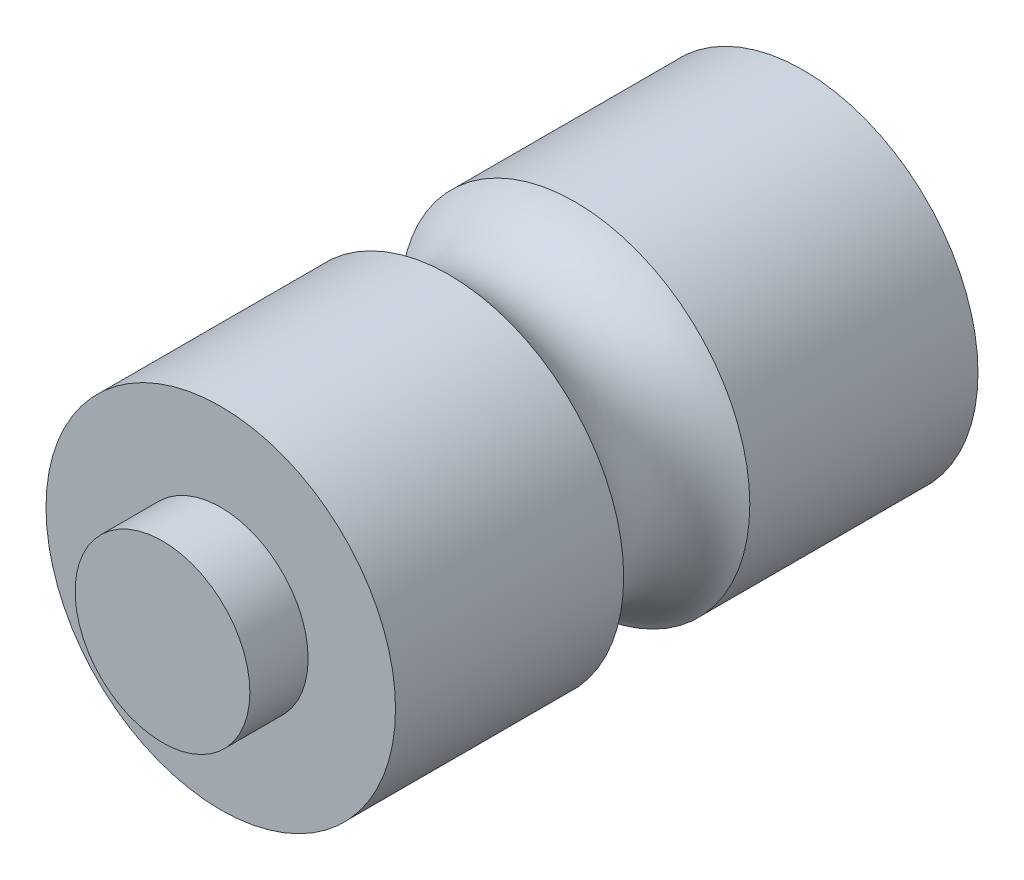
from build123d import *

# Parameters (mm, degrees)
SKETCH1_R           = 7.62
BOSS_EXTRUDE1_DEPTH = 25.4
SKETCH3_R           = 3.81
BOSS_EXTRUDE2_DEPTH = 2.54
SKETCH4_R           = 3.81
BOSS_EXTRUDE3_DEPTH = 2.54


with BuildPart() as part:
    # Sketch1 → Boss-Extrude1 (new body)
    with BuildSketch(Plane.XY):
        Circle(SKETCH1_R)
    extrude(amount=BOSS_EXTRUDE1_DEPTH)

    # Cut-Sweep1: sweep along a curve in space
    with BuildLine() as cut_sweep1_path:
        ThreePointArc((7.62, 0, 0), (5.388153673, 5.388153673, 0), (0, 7.62, 0))
        ThreePointArc((0, 7.62, 0), (-5.388153673, 5.388153673, 0), (-7.62, 0, 0))
        ThreePointArc((-7.62, 0, 0), (-5.388153673, -5.388153673, 0), (0, -7.62, 0))
        ThreePointArc((0, -7.62, 0), (5.388153673, -5.388153673, 0), (7.62, 0, 0))
    # Sketch2 → Cut-Sweep1 (sweep, cut)
    with BuildSketch(Plane(origin=(0, 0, 0), x_dir=(1, 0, 0), z_dir=(0, 1, 0))):
        with BuildLine():
            Line((7.62, -9.950369343), (7.62, -15.449630657))
            ThreePointArc((7.62, -15.449630657), (6.0325, -12.7), (7.62, -9.950369343))
        make_face()
    sweep(path=cut_sweep1_path.line, mode=Mode.SUBTRACT)

    # Sketch3 → Boss-Extrude2 (add)
    with BuildSketch(Plane.XY.offset(25.4)):
        Circle(SKETCH3_R)
    extrude(amount=BOSS_EXTRUDE2_DEPTH)

    # Sketch4 → Boss-Extrude3 (add)
    with BuildSketch(Plane(origin=(0, 0, 0), x_dir=(-1, 0, 0), z_dir=(0, 0, -1))):
        with Locations(Location((0, 0, 0), (0, 0, 180))):
            Circle(SKETCH4_R)
    extrude(amount=BOSS_EXTRUDE3_DEPTH)


solid = part.part
